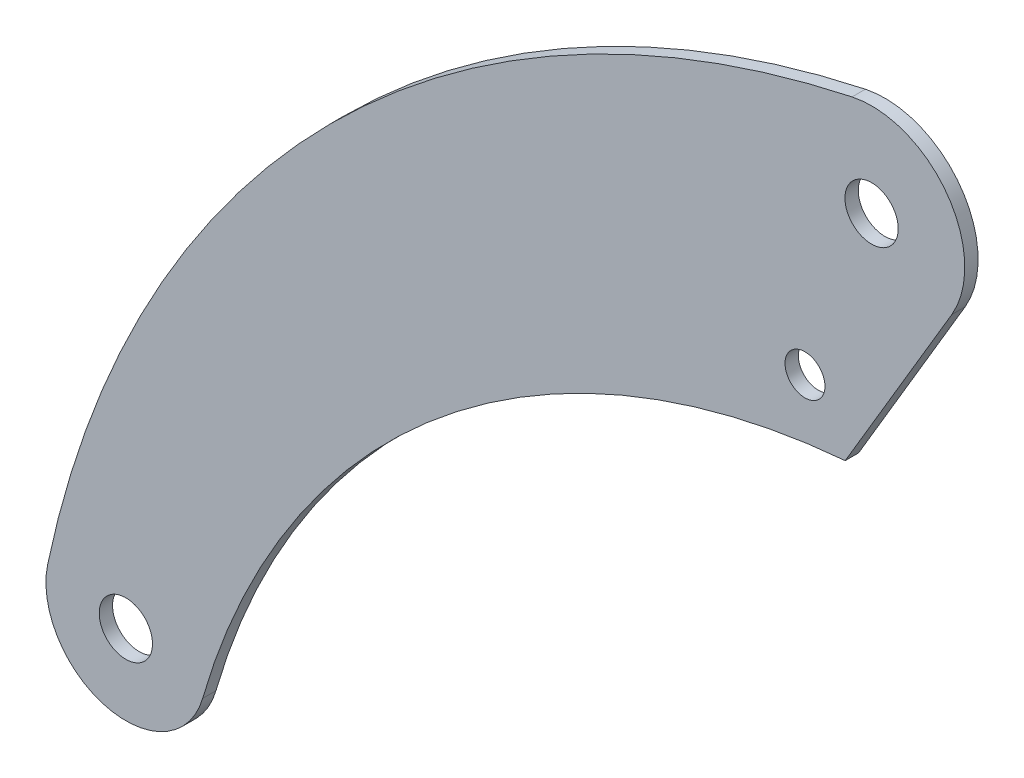
from build123d import *

# Parameters (mm, degrees)
SKETCH1_R           = 20
SKETCH1_R_2         = 15
BOSS_EXTRUDE1_DEPTH = 5


with BuildPart() as part:
    # Sketch1 → Boss-Extrude1 (new body, symmetric)
    with BuildSketch(Plane.XY):
        with BuildLine():
            Line((60.220407354, -35.686167321), (-19.779592646, -170.686167321))
            ThreePointArc((-19.779592646, -170.686167321), (-322.664914871, -293.556077803), (-502.341900983, -566.599506551))
            ThreePointArc((-502.341900983, -566.599506551), (-574.483190404, -608.225743411), (-618.715737076, -537.652440745))
            ThreePointArc((-618.715737076, -537.652440745), (-406.524759245, -145.05016338), (-14.634584071, 68.45311497))
            ThreePointArc((-14.634584071, 68.45311497), (56.839813073, 40.856280421), (60.220407354, -35.686167321))
        make_face()
        Circle(SKETCH1_R, mode=Mode.SUBTRACT)
        with Locations((-50, -130)):
            Circle(SKETCH1_R_2, mode=Mode.SUBTRACT)
        with Locations((-560, -550)):
            Circle(SKETCH1_R, mode=Mode.SUBTRACT)
    extrude(amount=BOSS_EXTRUDE1_DEPTH, both=True)


solid = part.part
